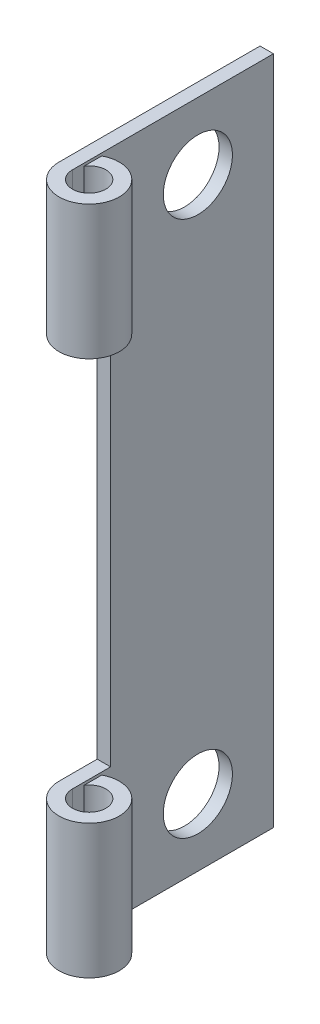
from build123d import *

# Parameters (mm, degrees)
BOSS_EXTRUDE1_DEPTH = 31.75
SKETCH7_W           = 3.6195
SKETCH7_H           = 6.35
CUT_EXTRUDE2_DEPTH  = 3.8575
SKETCH10_W          = 3.6195
SKETCH10_H          = 6.35
CUT_EXTRUDE4_DEPTH  = 3.8575
SKETCH15_R          = 1.6383
CUT_EXTRUDE5_DEPTH  = 3.8575


with BuildPart() as part:
    # Sketch3 → Boss-Extrude1 (new body)
    with BuildSketch(Plane(origin=(0, 0, 0), x_dir=(1, 0, 0), z_dir=(0, 1, 0))):
        with BuildLine():
            Line((0.635, 9.525), (0, 9.525))
            Line((0, 9.525), (0, 0))
            ThreePointArc((0, 0), (2.652258403, -0.737803327), (0.762, 1.263634045))
            Line((0.762, 1.263634045), (0.762, 0.430677954))
            ThreePointArc((0.762, 0.430677954), (2.190088254, -0.224506403), (0.635, 0))
            Line((0.635, 0), (0.635, 9.525))
        make_face()
    extrude(amount=BOSS_EXTRUDE1_DEPTH)

    # Sketch7 → Cut-Extrude2 (cut, through all)
    with BuildSketch(Plane(origin=(0, 0, 0), x_dir=(0, 0, -1), z_dir=(1, 0, 0))):
        with Locations((0, 34.925)):
            Rectangle(SKETCH7_W, SKETCH7_H)
        with Locations((0, 9.525)):
            Rectangle(SKETCH7_W, SKETCH7_H)
        with Locations((0, 22.225)):
            Rectangle(SKETCH7_W, SKETCH7_H)
    extrude(amount=CUT_EXTRUDE2_DEPTH, mode=Mode.SUBTRACT)

    # Sketch10 → Cut-Extrude4 (cut, through all)
    with BuildSketch(Plane(origin=(0, 0, 0), x_dir=(0, 0, -1), z_dir=(1, 0, 0))):
        with Locations((0, 15.875)):
            Rectangle(SKETCH10_W, SKETCH10_H)
    extrude(amount=CUT_EXTRUDE4_DEPTH, mode=Mode.SUBTRACT)

    # Sketch15 → Cut-Extrude5 (cut, through all)
    with BuildSketch(Plane(origin=(0, 0, 0), x_dir=(0, 0, -1), z_dir=(1, 0, 0))):
        with Locations((5.9436, 3.175)):
            Circle(SKETCH15_R)
    cut_extrude5 = extrude(amount=CUT_EXTRUDE5_DEPTH, mode=Mode.SUBTRACT)

    # Mirror1: Cut-Extrude5 across plane
    add(cut_extrude5.mirror(Plane(origin=(0, 15.875, 0), x_dir=(0, 0, 1), z_dir=(0, -1, 0))), mode=Mode.SUBTRACT)


solid = part.part
